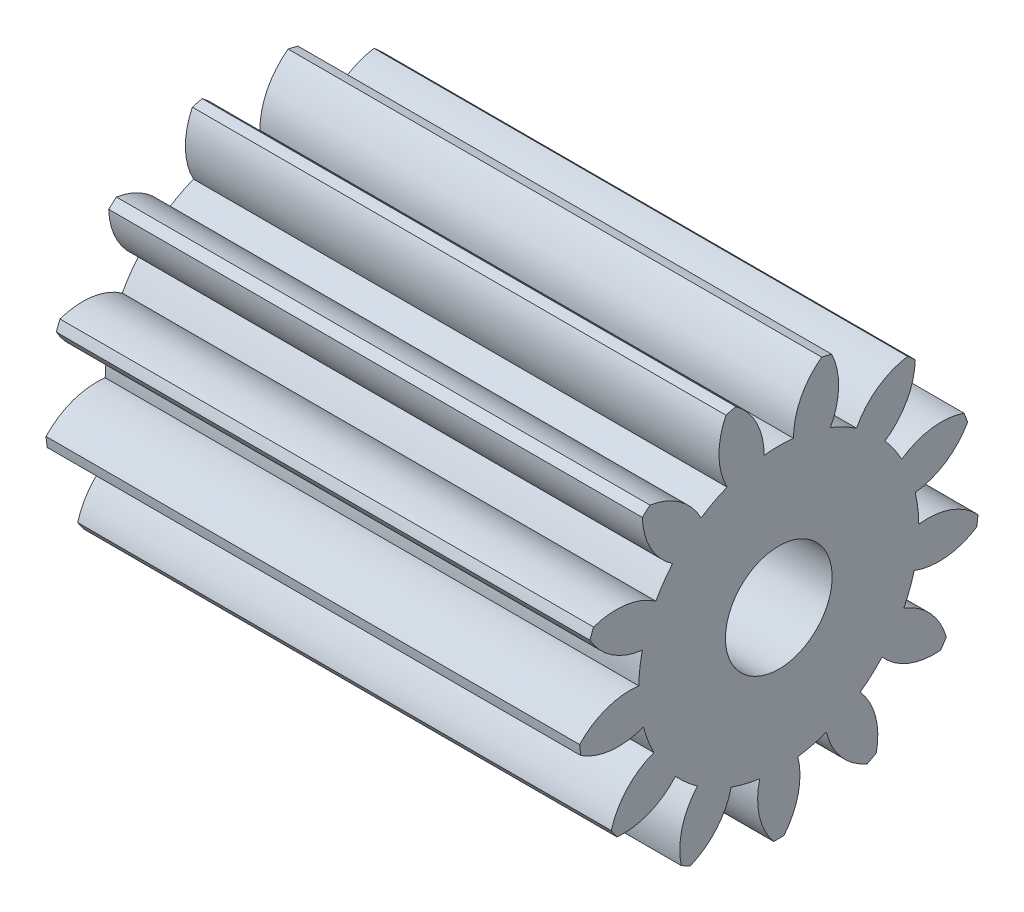
from build123d import *

# Parameters (mm, degrees)
BASPROSKE_W     = 10
BASPROSKE_H     = 3.75
TOOTHCUT_DEPTH  = 12.319231423
TEETHCUTS_COUNT = 13
TEETHCUTS_ANGLE = 332.307692308
BORSKE_R        = 1
BORE_DEPTH      = 50.0000508


with BuildPart() as part:
    # BasProSke → Base-Revolve (revolve)
    with BuildSketch(Plane(origin=(0, 0, 0), x_dir=(1, 0, 0), z_dir=(0, 1, 0)), mode=Mode.PRIVATE) as base_revolve_sk:
        with Locations((5, 1.875)):
            Rectangle(BASPROSKE_W, BASPROSKE_H)
    revolve(base_revolve_sk.sketch.rotate(Axis((-10, 0, 0), (1, 0, 0)), 180), axis=Axis((-10, 0, 0), (1, 0, 0)))

    # TooCutSke → ToothCut (cut, through all)
    with BuildSketch(Plane(origin=(0, 0, 0), x_dir=(0, 0, -1), z_dir=(1, 0, 0))):
        with BuildLine():
            ThreePointArc((0.275247387, 2.609523879), (0, 2.624), (-0.275247387, 2.609523879))
            ThreePointArc((-0.275247387, 2.609523879), (-0.421084752, 3.214694797), (-0.831556081, 3.682683756))
            ThreePointArc((-0.831556081, 3.682683756), (0, 3.7754), (0.831556081, 3.682683756))
            ThreePointArc((0.831556081, 3.682683756), (0.421084752, 3.214694797), (0.275247387, 2.609523879))
        make_face()
    toothcut = extrude(amount=TOOTHCUT_DEPTH, mode=Mode.SUBTRACT)

    # TeethCuts: ToothCut ×13 about axis
    teethcuts_axis = Axis((-10, 0, 0), (1, 0, 0))
    for i in range(1, TEETHCUTS_COUNT):
        add(toothcut.rotate(teethcuts_axis, i * TEETHCUTS_ANGLE / (TEETHCUTS_COUNT - 1)), mode=Mode.SUBTRACT)

    # BorSke → Bore (cut, symmetric)
    with BuildSketch(Plane(origin=(0, 0, 0), x_dir=(0, 0, -1), z_dir=(1, 0, 0))):
        with Locations(Location((0, 0, 0), (0, 0, 180))):
            Circle(BORSKE_R)
    extrude(amount=BORE_DEPTH, both=True, mode=Mode.SUBTRACT)


solid = part.part
